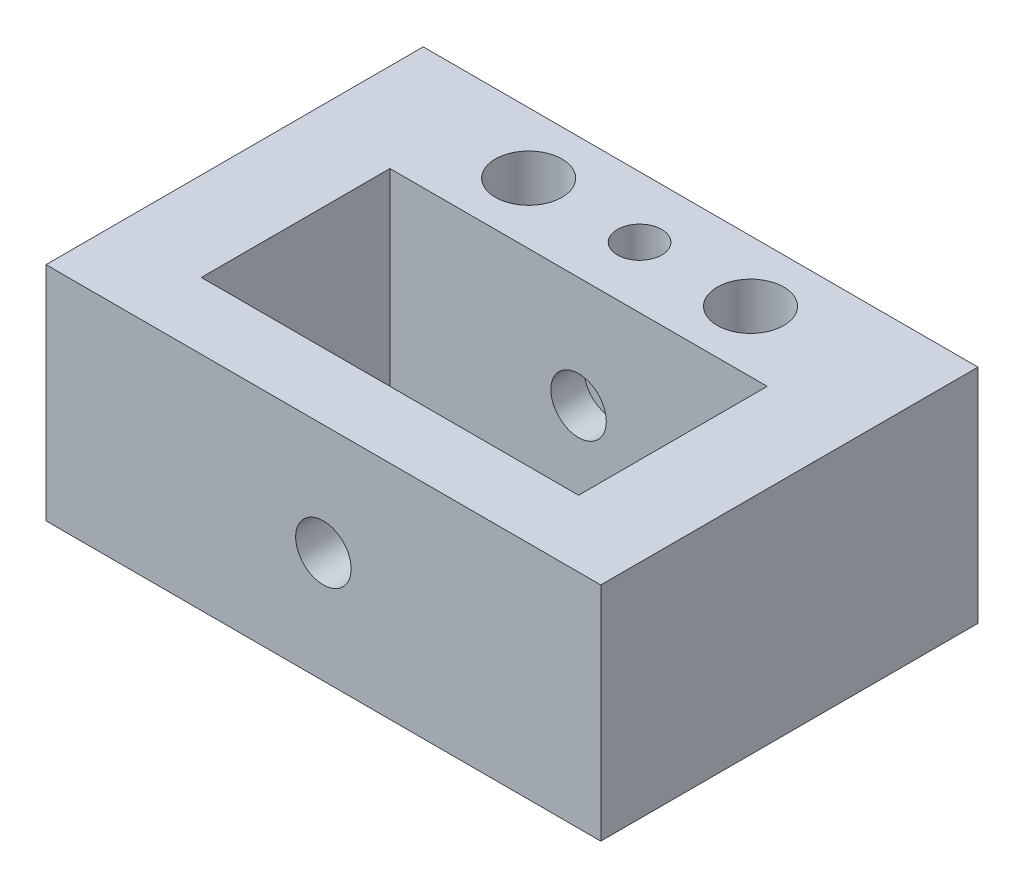
from build123d import *

# Parameters (mm, degrees)
SKETCH1_W                = 50
SKETCH1_H                = 20
BOSS_EXTRUDE1_DEPTH      = 11
SKETCH2_R                = 2
CUT_EXTRUDE1_DEPTH       = 11
SKETCH3_R                = 2
CUT_EXTRUDE2_DEPTH       = 21
SKETCH4_R                = 3
CUT_EXTRUDE3_DEPTH       = 21
SKETCH5_W                = 8
SKETCH5_H                = 20
BOSS_EXTRUDE2_DEPTH      = 22
SKETCH13_R               = 2.5
CUT_EXTRUDE6_DEPTH       = 3
SKETCH14_W               = 50
SKETCH14_H               = 20
BOSS_EXTRUDE4_DEPTH      = 1
BOSS_EXTRUDE4_DEPTH_BACK = 5
SKETCH15_R               = 2.5
CUT_EXTRUDE7_DEPTH       = 6
SKETCH18_R               = 2
CUT_EXTRUDE8_DEPTH       = 13


with BuildPart() as part:
    # Sketch1 → Boss-Extrude1 (new body)
    with BuildSketch(Plane.XY):
        Rectangle(SKETCH1_W, SKETCH1_H)
    extrude(amount=BOSS_EXTRUDE1_DEPTH)

    # Sketch2 → Cut-Extrude1 (cut)
    with BuildSketch(Plane(origin=(0, 0, 0), x_dir=(-1, 0, 0), z_dir=(0, 0, -1))):
        with Locations((-20, 0)):
            Circle(SKETCH2_R)
        with Locations((20, 0)):
            Circle(SKETCH2_R)
    extrude(amount=-CUT_EXTRUDE1_DEPTH, mode=Mode.SUBTRACT)

    # Sketch3 → Cut-Extrude2 (cut, through all)
    with BuildSketch(Plane.XZ.offset(10)):
        with Locations((0, 5.5)):
            Circle(SKETCH3_R)
    extrude(amount=-CUT_EXTRUDE2_DEPTH, mode=Mode.SUBTRACT)

    # Sketch4 → Cut-Extrude3 (cut, through all)
    with BuildSketch(Plane.XZ.offset(10)):
        with Locations((-10, 5.5)):
            Circle(SKETCH4_R)
        with Locations((10, 5.5)):
            Circle(SKETCH4_R)
    extrude(amount=-CUT_EXTRUDE3_DEPTH, mode=Mode.SUBTRACT)

    # Sketch5 → Boss-Extrude2 (add)
    with BuildSketch(Plane.XY.offset(11)):
        with Locations((-21, 0)):
            Rectangle(SKETCH5_W, SKETCH5_H)
        with Locations((21, 0)):
            Rectangle(SKETCH5_W, SKETCH5_H)
    extrude(amount=BOSS_EXTRUDE2_DEPTH)

    # Sketch13 → Cut-Extrude6 (cut)
    with BuildSketch(Plane.XY.offset(11)):
        Circle(SKETCH13_R)
    extrude(amount=-CUT_EXTRUDE6_DEPTH, mode=Mode.SUBTRACT)

    # Sketch14 → Boss-Extrude4 (add, two sides)
    with BuildSketch(Plane.XY.offset(33)) as boss_extrude4_sk:
        Rectangle(SKETCH14_W, SKETCH14_H)
    extrude(amount=BOSS_EXTRUDE4_DEPTH)
    extrude(boss_extrude4_sk.sketch, amount=-BOSS_EXTRUDE4_DEPTH_BACK)

    # Sketch15 → Cut-Extrude7 (cut)
    with BuildSketch(Plane.XY.offset(34)):
        Circle(SKETCH15_R)
    extrude(amount=-CUT_EXTRUDE7_DEPTH, mode=Mode.SUBTRACT)

    # Sketch18 → Cut-Extrude8 (cut)
    with BuildSketch(Plane(origin=(0, 0, 11), x_dir=(-1, 0, 0), z_dir=(0, 0, -1))):
        with Locations((-20, 0)):
            Circle(SKETCH18_R)
        with Locations((20, 0)):
            Circle(SKETCH18_R)
    extrude(amount=-CUT_EXTRUDE8_DEPTH, mode=Mode.SUBTRACT)


solid = part.part
